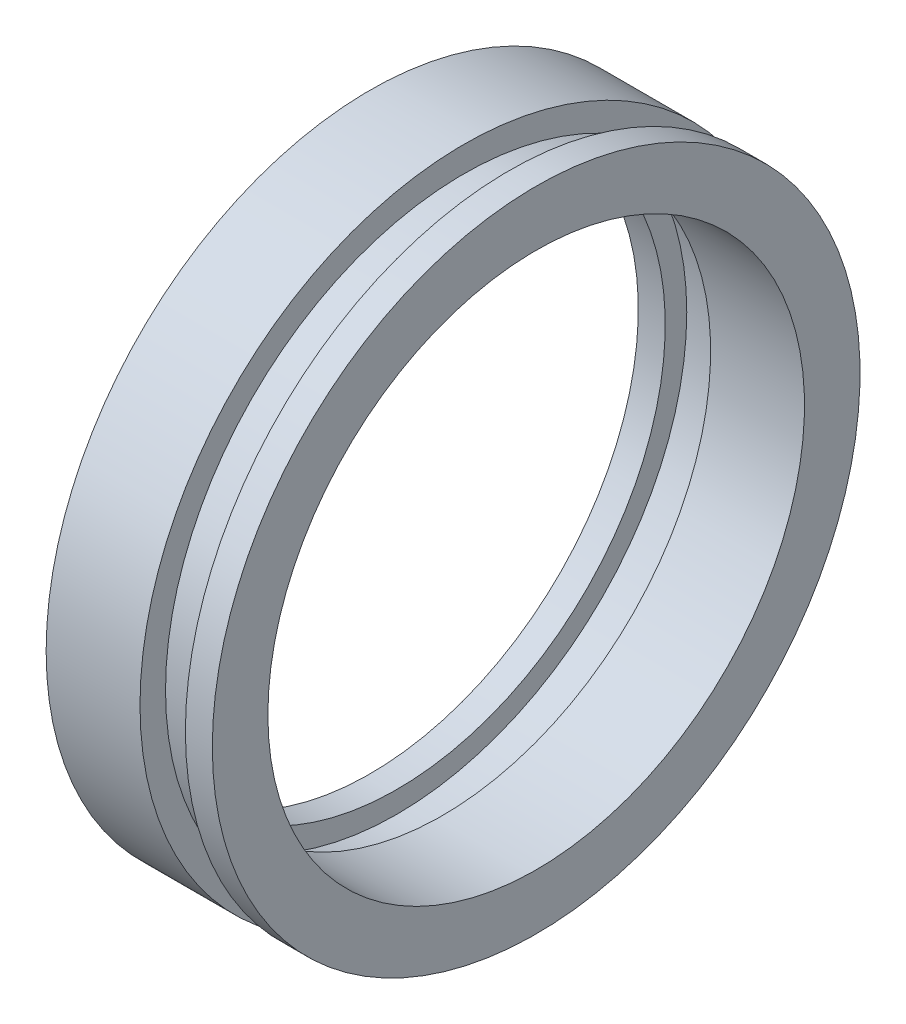
from build123d import *


with BuildPart() as part:
    # Sketch1 → Revolve1 (revolve)
    with BuildSketch(Plane.XY):
        Polygon((0, 28.829), (0, 34.798), (10.0838, 34.798), (10.0838, 32.0548), (14.9606, 32.0548), (14.9606, 34.798), (17.8562, 34.798), (17.8562, 28.829), (7.7724, 28.829), (7.7724, 31.1404), (2.8956, 31.1404), (2.8956, 28.829), align=None)
    revolve(axis=Axis((0, 0, 0), (1, 0, 0)))


solid = part.part
